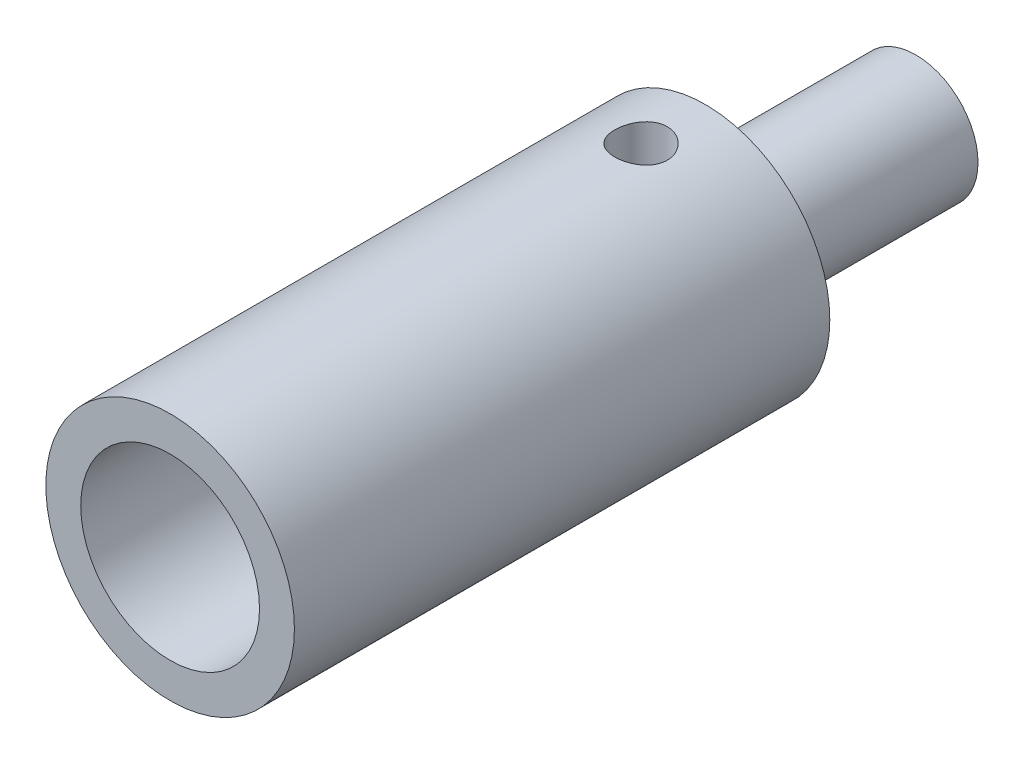
from build123d import *

# Parameters (mm, degrees)
CROQUIS1_R                 = 13
CROQUIS1_R_2               = 9.35
SALIENTE_EXTRUIR1_DEPTH    = 40
SALIENTE_EXTRUIR2_START    = -16
CROQUIS1_2_R               = 13
SALIENTE_EXTRUIR2_DEPTH    = 16
CROQUIS2_R                 = 6.5
SALIENTE_EXTRUIR3_DEPTH    = 22
REDONDEO1_R                = 0.5
REDONDEO2_R                = 0.5
CORTAR_EXTRUIR1_DEPTH      = 45.022721406
CORTAR_EXTRUIR1_DEPTH_BACK = 45.022721406
CROQUIS3_R                 = 2.75


with BuildPart() as part:
    # Croquis1 → Saliente-Extruir1 (new body)
    with BuildSketch(Plane.XY):
        Circle(CROQUIS1_R)
        Circle(CROQUIS1_R_2, mode=Mode.SUBTRACT)
    extrude(amount=SALIENTE_EXTRUIR1_DEPTH)

    # Croquis1_2 → Saliente-Extruir2 (add)
    with BuildSketch(Plane.XY.offset(SALIENTE_EXTRUIR2_START)):
        Circle(CROQUIS1_2_R)
    extrude(amount=SALIENTE_EXTRUIR2_DEPTH)

    # Croquis2 → Saliente-Extruir3 (add)
    with BuildSketch(Plane(origin=(0, 0, -16), x_dir=(-1, 0, 0), z_dir=(0, 0, -1))):
        Circle(CROQUIS2_R)
    extrude(amount=SALIENTE_EXTRUIR3_DEPTH)

    # Redondeo1
    redondeo1_edges = [part.edges().sort_by_distance(p)[0] for p in [
        (6.5, 0, -16),
    ]]
    fillet(redondeo1_edges, radius=REDONDEO1_R)

    # Redondeo2
    redondeo2_edges = [part.edges().sort_by_distance(p)[0] for p in [
        (-9.35, 0, 0),
    ]]
    fillet(redondeo2_edges, radius=REDONDEO2_R)

    # Croquis3 → Cortar-Extruir1 (cut, two sides: drawn at the far end of the back side and taken through both)
    with BuildSketch(Plane(origin=(0, 0, 0), x_dir=(1, 0, 0), z_dir=(0, 1, 0)).offset(-CORTAR_EXTRUIR1_DEPTH_BACK)):
        with Locations((0, 9.25)):
            Circle(CROQUIS3_R)
    extrude(amount=CORTAR_EXTRUIR1_DEPTH + CORTAR_EXTRUIR1_DEPTH_BACK, mode=Mode.SUBTRACT)


solid = part.part
